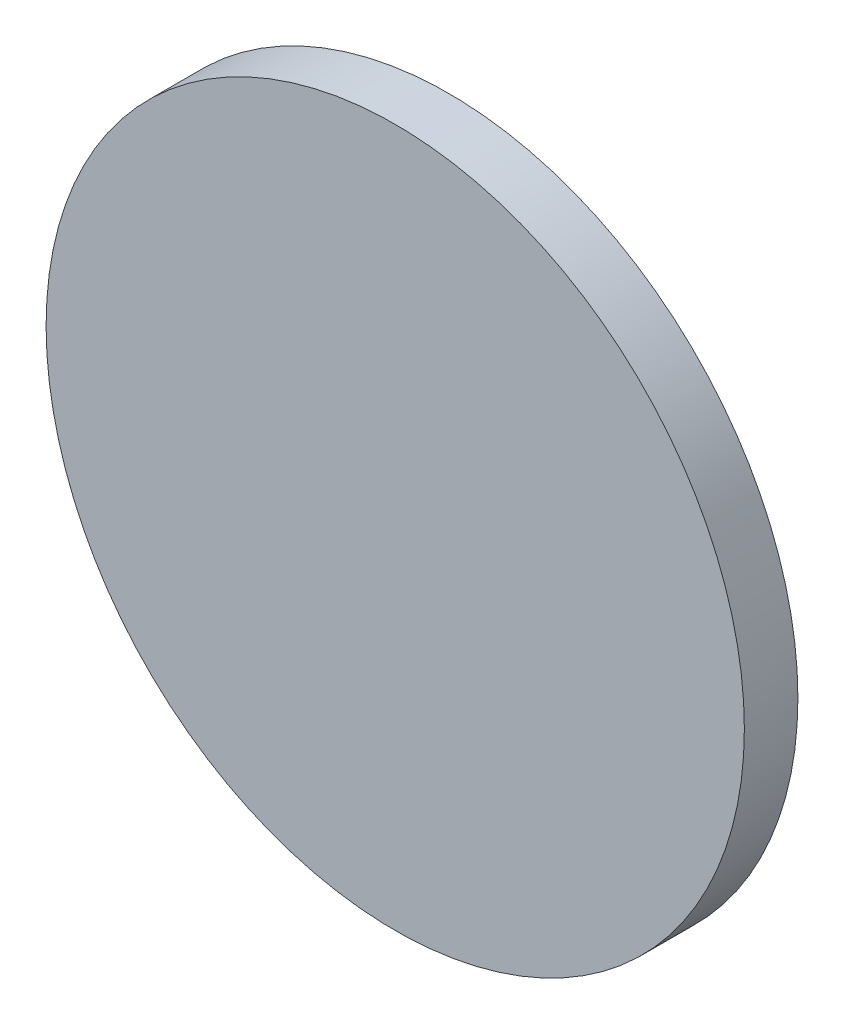
from build123d import *

# Parameters (mm, degrees)
SKETCH_1_R      = 15
EXTRUDE_1_DEPTH = 2.3


with BuildPart() as part:
    # 草图1 → 凸台-拉伸1 (new body)
    with BuildSketch(Plane.XY):
        with Locations((108.614983942, 61.563241835)):
            Circle(SKETCH_1_R)
    extrude(amount=EXTRUDE_1_DEPTH)


solid = part.part
